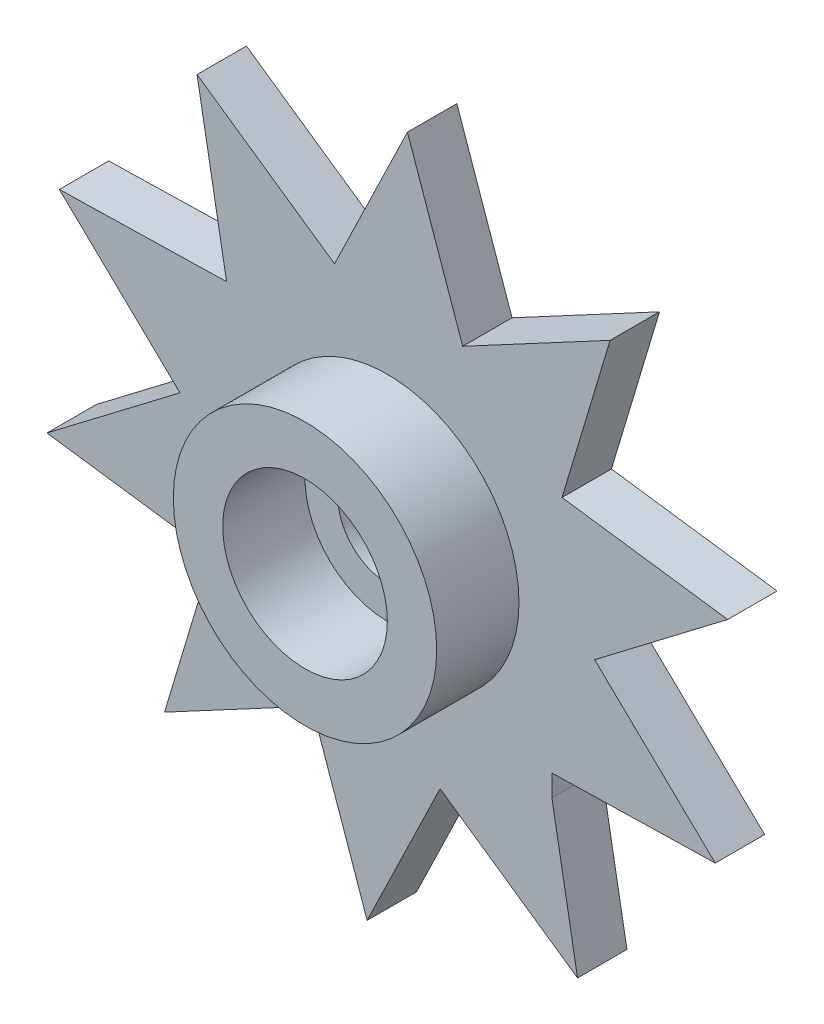
from build123d import *

# Parameters (mm, degrees)
BOSS_EXTRU_1_DEPTH                                = 1.5
ESQUISSE2_W                                       = 4
ESQUISSE2_H                                       = 2.5
CHAMBRAGE_POUR_VIS_T_TE_HEXAGONALE_M2_D           = 3
CHAMBRAGE_POUR_VIS_T_TE_HEXAGONALE_M2_DEPTH       = 4
CHAMBRAGE_POUR_VIS_T_TE_HEXAGONALE_M2_CBORE_D     = 5
CHAMBRAGE_POUR_VIS_T_TE_HEXAGONALE_M2_CBORE_DEPTH = 2.5
CHANFREIN1_SIZE                                   = 0.66150504
CHANFREIN1_SIZE2                                  = 0.116617787


with BuildPart() as part:
    # Esquisse1 → Boss.-Extru.1 (new body)
    with BuildSketch(Plane.XY):
        Polygon((-27.097787955, 20.402380339), (-22.922211673, 17.509970722), (-23.817460632, 22.509970718), (-18.739232742, 22.624304328), (-22.402430623, 26.143175168), (-18.36126158, 29.220580467), (-23.393191293, 29.914233086), (-21.932670307, 34.779245838), (-26.411305743, 32.382728509), (-28.089302186, 37.177079198), (-30.303956824, 32.605780103), (-34.479533107, 35.49818972), (-33.584284152, 30.498189734), (-38.662512037, 30.383856115), (-34.999314157, 26.864985274), (-39.040483199, 23.787579976), (-34.008553486, 23.093927357), (-35.469074473, 18.228914604), (-30.990439036, 20.625431934), (-29.312442593, 15.831081245), align=None)
    extrude(amount=-BOSS_EXTRU_1_DEPTH)

    # Esquisse2 → Révolution1 (revolve)
    with BuildSketch(Plane.XZ.offset(-26.504080221)):
        with Locations((-26.70087239, 1.25)):
            Rectangle(ESQUISSE2_W, ESQUISSE2_H)
    revolve(axis=Axis((-28.70087239, 26.504080221, 2.5), (0, 0, -1)))

    # Chambrage pour vis à tête hexagonale M2.51
    with Locations(Plane.XY.offset(2.5)):
        with Locations((-28.70087239, 26.504080221)):
            CounterBoreHole(CHAMBRAGE_POUR_VIS_T_TE_HEXAGONALE_M2_D / 2, CHAMBRAGE_POUR_VIS_T_TE_HEXAGONALE_M2_CBORE_D / 2, CHAMBRAGE_POUR_VIS_T_TE_HEXAGONALE_M2_CBORE_DEPTH, depth=CHAMBRAGE_POUR_VIS_T_TE_HEXAGONALE_M2_DEPTH)

    # Chanfrein1
    chanfrein1_edges = [part.edges().sort_by_distance(p)[0] for p in [
        (-23.817460632, 22.509970718, -0.75),
    ]]
    chanfrein1_side = [part.faces().sort_by_distance(p)[0] for p in [
        (-23.369836152, 20.00997072, -0.75),
    ]]
    chamfer(chanfrein1_edges, length=CHANFREIN1_SIZE, length2=CHANFREIN1_SIZE2, reference=chanfrein1_side[0])


solid = part.part
